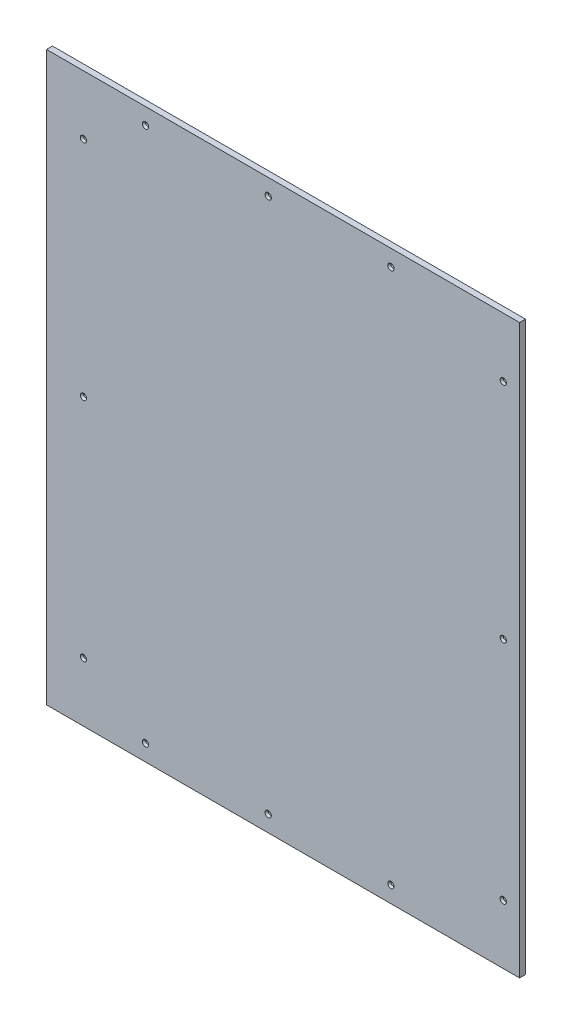
from build123d import *

# Parameters (mm, degrees)
SKETCH1_W                                           = 1016
SKETCH1_H                                           = 1219.2
BOSS_EXTRUDE1_DEPTH                                 = 12.7
SKETCH2_R                                           = 3.302
SKETCH2_R_2                                         = 3.175
CUT_EXTRUDE1_DEPTH                                  = 12.7
CSK_FOR_1_4_FLAT_HEAD_SOCKET_CAP_SCREW1_D           = 6.7564
CSK_FOR_1_4_FLAT_HEAD_SOCKET_CAP_SCREW1_CSINK_D     = 13.4874
CSK_FOR_1_4_FLAT_HEAD_SOCKET_CAP_SCREW1_CSINK_ANGLE = 82


with BuildPart() as part:
    # Sketch1 → Boss-Extrude1 (new body)
    with BuildSketch(Plane.XY):
        with Locations((-614.288814817, 609.6)):
            Rectangle(SKETCH1_W, SKETCH1_H)
    extrude(amount=BOSS_EXTRUDE1_DEPTH)

    # Sketch2 → Cut-Extrude1 (cut)
    with BuildSketch(Plane(origin=(0, 0, 0), x_dir=(-1, 0, 0), z_dir=(0, 0, -1))):
        with Locations((382.640814817, 1184.275)):
            Circle(SKETCH2_R)
        with Locations((646.165814817, 1184.275)):
            Circle(SKETCH2_R)
        with Locations((909.690814817, 1184.275)):
            Circle(SKETCH2_R)
        with Locations((1042.914014184, 1092.073)):
            Circle(SKETCH2_R_2)
        with Locations((1042.914014184, 612.775)):
            Circle(SKETCH2_R_2)
        with Locations((1042.914014184, 127)):
            Circle(SKETCH2_R_2)
        with Locations((141.213814817, 127.127)):
            Circle(SKETCH2_R_2)
        with Locations((141.213814817, 612.775)):
            Circle(SKETCH2_R)
        with Locations((141.213814817, 1092.073)):
            Circle(SKETCH2_R_2)
        with Locations((909.690814817, 34.925)):
            Circle(SKETCH2_R)
        with Locations((646.165814817, 34.925)):
            Circle(SKETCH2_R)
        with Locations((382.640814817, 34.925)):
            Circle(SKETCH2_R)
    extrude(amount=-CUT_EXTRUDE1_DEPTH, mode=Mode.SUBTRACT)

    # CSK for 1/4 Flat Head Socket Cap Screw1 (through all)
    with Locations(Plane(origin=(-909.690814817, 1184.275, 12.7), x_dir=(1, 0, 0), z_dir=(0, 0, 1))):
        with Locations((0, 0), (263.525, 0), (527.05, 0), (768.477, -92.202), (768.477, -571.5), (768.477, -1057.148), (527.05, -1149.35), (263.525, -1149.35), (0, -1149.35), (-133.223199367, -1057.275), (-133.223199367, -571.5), (-133.223199367, -92.202)):
            CounterSinkHole(CSK_FOR_1_4_FLAT_HEAD_SOCKET_CAP_SCREW1_D / 2, CSK_FOR_1_4_FLAT_HEAD_SOCKET_CAP_SCREW1_CSINK_D / 2, counter_sink_angle=CSK_FOR_1_4_FLAT_HEAD_SOCKET_CAP_SCREW1_CSINK_ANGLE)


solid = part.part
